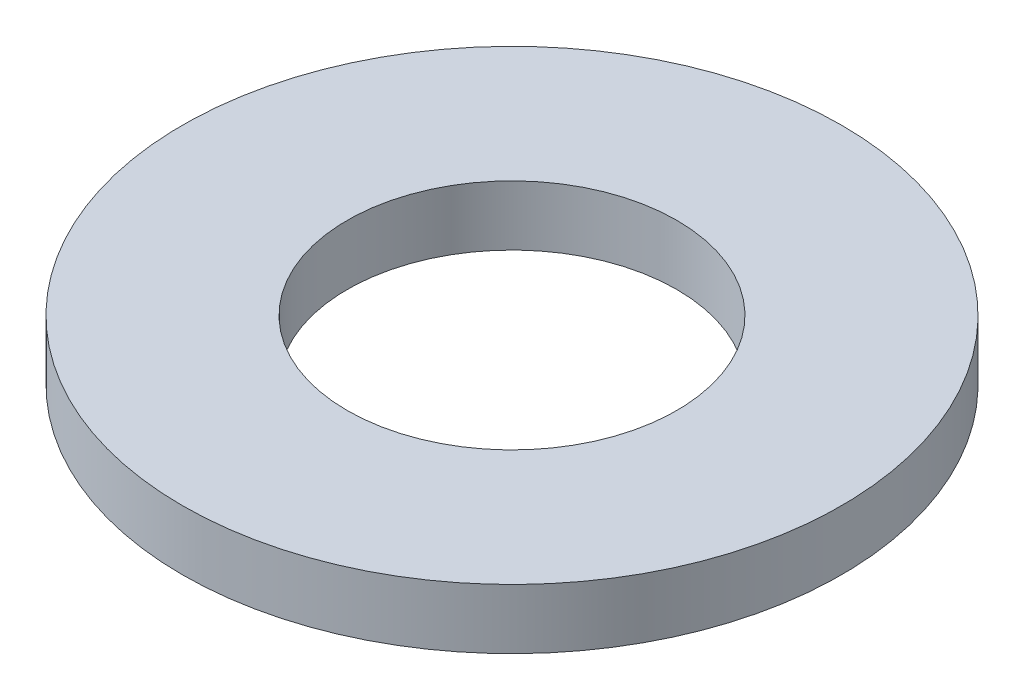
from build123d import *

# Parameters (mm, degrees)
ESBO_O1_R                = 4.4
ESBO_O1_R_2              = 2.2
RESSALTO_EXTRUS_O1_DEPTH = 0.8


with BuildPart() as part:
    # Esboço1 → Ressalto-extrusão1 (new body)
    with BuildSketch(Plane(origin=(0, 0, 0), x_dir=(1, 0, 0), z_dir=(0, 1, 0))):
        Circle(ESBO_O1_R)
        Circle(ESBO_O1_R_2, mode=Mode.SUBTRACT)
    extrude(amount=RESSALTO_EXTRUS_O1_DEPTH)


solid = part.part
